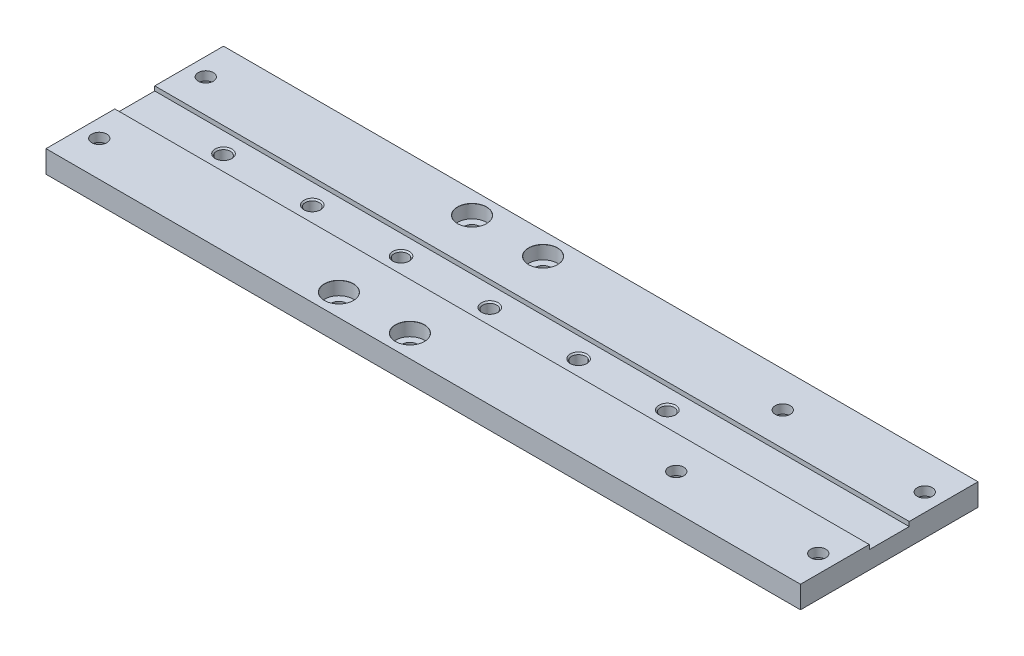
from build123d import *

# Parameters (mm, degrees)
ESBO_O1_W                                         = 170
ESBO_O1_H                                         = 40
RESSALTO_EXTRUS_O1_DEPTH                          = 5
ESBO_O2_W                                         = 170
ESBO_O2_H                                         = 9
CORTE_EXTRUS_O1_DEPTH                             = 1
REBAIXO_PARA_SHCS_M31_AT_2_COUNT                  = 2
REBAIXO_PARA_SHCS_M31_AT_2_PITCH                  = 24
REBAIXO_PARA_SHCS_M31_AT_3_COUNT                  = 2
REBAIXO_PARA_SHCS_M31_AT_3_PITCH                  = 130
REBAIXO_PARA_SHCS_M31_AT_4_COUNT                  = 2
REBAIXO_PARA_SHCS_M31_AT_4_PITCH                  = 132.196822957
REBAIXO_PARA_SHCS_M31_AT_5_COUNT                  = 2
REBAIXO_PARA_SHCS_M31_AT_5_PITCH                  = 162
REBAIXO_PARA_SHCS_M31_AT_6_COUNT                  = 2
REBAIXO_PARA_SHCS_M31_AT_6_PITCH                  = 163.768128767
REBAIXO_PARA_SHCS_M32_AT_2_COUNT                  = 2
REBAIXO_PARA_SHCS_M32_AT_2_PITCH                  = 16
REBAIXO_PARA_SHCS_M32_AT_3_COUNT                  = 2
REBAIXO_PARA_SHCS_M32_AT_3_PITCH                  = 30
REBAIXO_PARA_SHCS_M32_AT_4_COUNT                  = 2
REBAIXO_PARA_SHCS_M32_AT_4_PITCH                  = 34
FURO_ROSCADO_PARA_CONDU_TE_DE_M3X0_51_D           = 3.15
FURO_ROSCADO_PARA_CONDU_TE_DE_M3X0_51_CSINK_D     = 3.766
FURO_ROSCADO_PARA_CONDU_TE_DE_M3X0_51_CSINK_ANGLE = 90


with BuildPart() as part:
    # Esboço1 → Ressalto-extrusão1 (new body)
    with BuildSketch(Plane(origin=(0, 0, 0), x_dir=(1, 0, 0), z_dir=(0, 1, 0))):
        Rectangle(ESBO_O1_W, ESBO_O1_H)
    extrude(amount=RESSALTO_EXTRUS_O1_DEPTH)

    # Esboço2 → Corte-extrusão1 (cut)
    with BuildSketch(Plane(origin=(0, 5, 0), x_dir=(1, 0, 0), z_dir=(0, 1, 0))):
        Rectangle(ESBO_O2_W, ESBO_O2_H)
    extrude(amount=-CORTE_EXTRUS_O1_DEPTH, mode=Mode.SUBTRACT)

    # Esboço4 → Rebaixo para SHCS M31 (revolve, cut)
    with BuildSketch(Plane(origin=(-81, 0, -12), x_dir=(0, 0, -1), z_dir=(1, 0, 0))):
        Polygon((0, 0), (0, 5), (1.7, 5), (1.7, 3), (3.25, 3), (3.25, 0.025), (3.275, 0), align=None)
    rebaixo_para_shcs_m31 = revolve(axis=Axis((-81, -6.35, -12), (0, 1, 0)), mode=Mode.SUBTRACT)

    # Rebaixo para SHCS M31 at 2: Rebaixo para SHCS M31 ×2
    with Locations(*[(0, 0, i * REBAIXO_PARA_SHCS_M31_AT_2_PITCH) for i in range(1, REBAIXO_PARA_SHCS_M31_AT_2_COUNT)]):
        add(rebaixo_para_shcs_m31, mode=Mode.SUBTRACT)

    # Rebaixo para SHCS M31 at 3: Rebaixo para SHCS M31 ×2
    with Locations(*[(i * REBAIXO_PARA_SHCS_M31_AT_3_PITCH, 0, 0) for i in range(1, REBAIXO_PARA_SHCS_M31_AT_3_COUNT)]):
        add(rebaixo_para_shcs_m31, mode=Mode.SUBTRACT)

    # Rebaixo para SHCS M31 at 4: Rebaixo para SHCS M31 ×2
    with Locations(*[Vector(0.98338218, 0, 0.181547479) * (i * REBAIXO_PARA_SHCS_M31_AT_4_PITCH) for i in range(1, REBAIXO_PARA_SHCS_M31_AT_4_COUNT)]):
        add(rebaixo_para_shcs_m31, mode=Mode.SUBTRACT)

    # Rebaixo para SHCS M31 at 5: Rebaixo para SHCS M31 ×2
    with Locations(*[(i * REBAIXO_PARA_SHCS_M31_AT_5_PITCH, 0, 0) for i in range(1, REBAIXO_PARA_SHCS_M31_AT_5_COUNT)]):
        add(rebaixo_para_shcs_m31, mode=Mode.SUBTRACT)

    # Rebaixo para SHCS M31 at 6: Rebaixo para SHCS M31 ×2
    with Locations(*[Vector(0.989203462, 0, 0.146548661) * (i * REBAIXO_PARA_SHCS_M31_AT_6_PITCH) for i in range(1, REBAIXO_PARA_SHCS_M31_AT_6_COUNT)]):
        add(rebaixo_para_shcs_m31, mode=Mode.SUBTRACT)

    # Esboço6 → Rebaixo para SHCS M32 (revolve, cut)
    with BuildSketch(Plane(origin=(-24, 5, -15), x_dir=(0, 0, 1), z_dir=(1, 0, 0))):
        Polygon((0, 0), (0, 5), (1.7, 5), (1.7, 3), (3.25, 3), (3.25, 0.025), (3.275, 0), align=None)
    rebaixo_para_shcs_m32 = revolve(axis=Axis((-24, 11.35, -15), (0, -1, 0)), mode=Mode.SUBTRACT)

    # Rebaixo para SHCS M32 at 2: Rebaixo para SHCS M32 ×2
    with Locations(*[(i * REBAIXO_PARA_SHCS_M32_AT_2_PITCH, 0, 0) for i in range(1, REBAIXO_PARA_SHCS_M32_AT_2_COUNT)]):
        add(rebaixo_para_shcs_m32, mode=Mode.SUBTRACT)

    # Rebaixo para SHCS M32 at 3: Rebaixo para SHCS M32 ×2
    with Locations(*[(0, 0, i * REBAIXO_PARA_SHCS_M32_AT_3_PITCH) for i in range(1, REBAIXO_PARA_SHCS_M32_AT_3_COUNT)]):
        add(rebaixo_para_shcs_m32, mode=Mode.SUBTRACT)

    # Rebaixo para SHCS M32 at 4: Rebaixo para SHCS M32 ×2
    with Locations(*[Vector(0.470588235, 0, 0.882352941) * (i * REBAIXO_PARA_SHCS_M32_AT_4_PITCH) for i in range(1, REBAIXO_PARA_SHCS_M32_AT_4_COUNT)]):
        add(rebaixo_para_shcs_m32, mode=Mode.SUBTRACT)

    # Furo roscado para conduíte de M3x0.51 (through all)
    with Locations(Plane(origin=(0, 4, 0), x_dir=(1, 0, 0), z_dir=(0, 1, 0))):
        with Locations((-65, 0), (-45, 0), (-25, 0), (35, 0), (-5, 0), (15, 0)):
            CounterSinkHole(FURO_ROSCADO_PARA_CONDU_TE_DE_M3X0_51_D / 2, FURO_ROSCADO_PARA_CONDU_TE_DE_M3X0_51_CSINK_D / 2, counter_sink_angle=FURO_ROSCADO_PARA_CONDU_TE_DE_M3X0_51_CSINK_ANGLE)


solid = part.part
